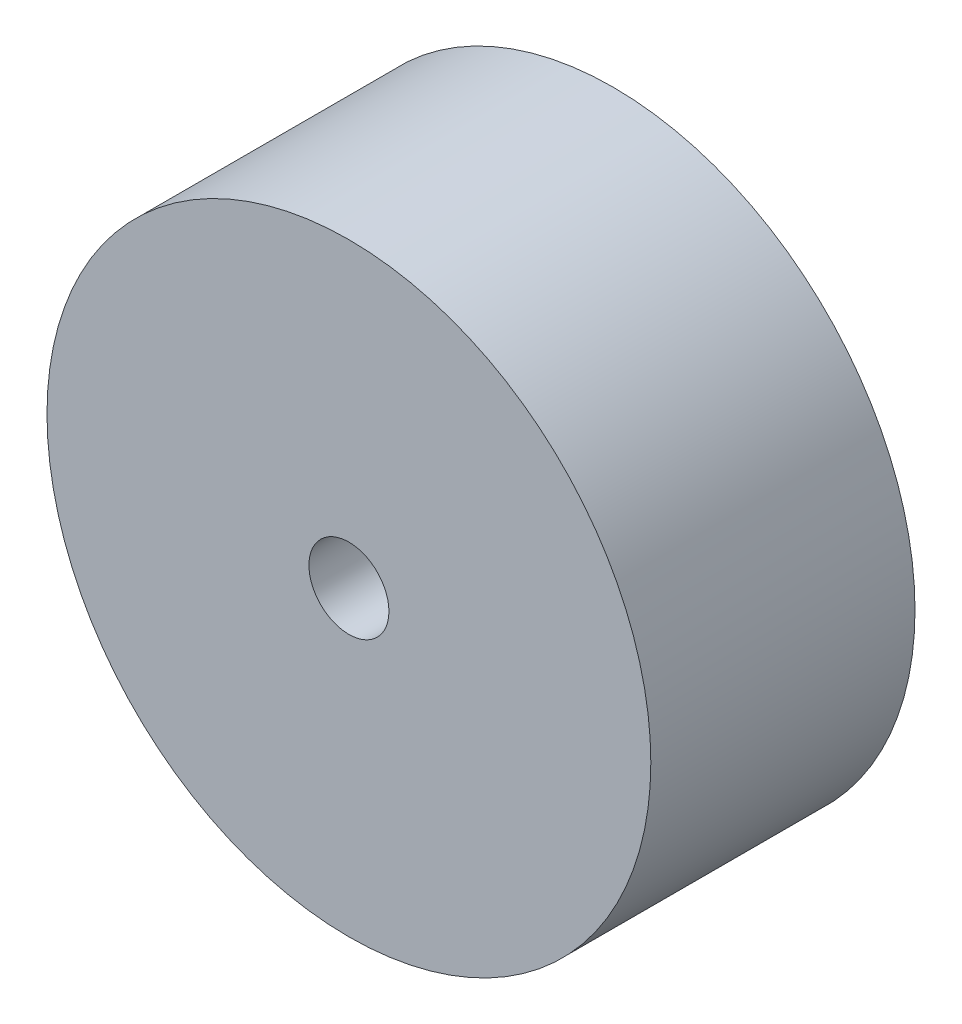
from build123d import *

# Parameters (mm, degrees)
SKETCH1_R           = 25.4
BOSS_EXTRUDE1_DEPTH = 22.225
SKETCH2_R           = 3.3655
CUT_EXTRUDE1_DEPTH  = 23.225


with BuildPart() as part:
    # Sketch1 → Boss-Extrude1 (new body)
    with BuildSketch(Plane.XY):
        Circle(SKETCH1_R)
    extrude(amount=BOSS_EXTRUDE1_DEPTH)

    # Sketch2 → Cut-Extrude1 (cut, through all)
    with BuildSketch(Plane.XY.offset(22.225)):
        Circle(SKETCH2_R)
    extrude(amount=-CUT_EXTRUDE1_DEPTH, mode=Mode.SUBTRACT)


solid = part.part
